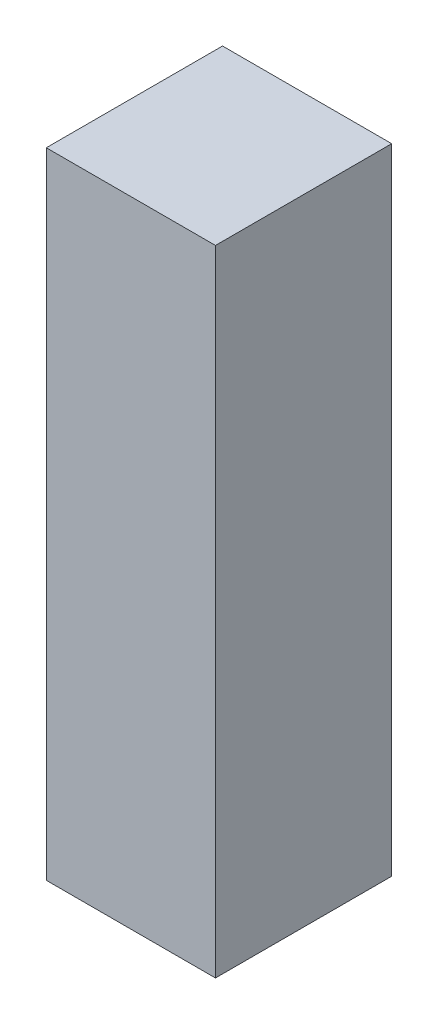
from build123d import *

# Parameters (mm, degrees)
SKETCH1_W           = 12
SKETCH1_H           = 12.5
BOSS_EXTRUDE1_DEPTH = 45


with BuildPart() as part:
    # Sketch1 → Boss-Extrude1 (new body)
    with BuildSketch(Plane(origin=(0, 0, 0), x_dir=(1, 0, 0), z_dir=(0, 1, 0))):
        with Locations((6, 6.25)):
            Rectangle(SKETCH1_W, SKETCH1_H)
    extrude(amount=BOSS_EXTRUDE1_DEPTH)


solid = part.part
